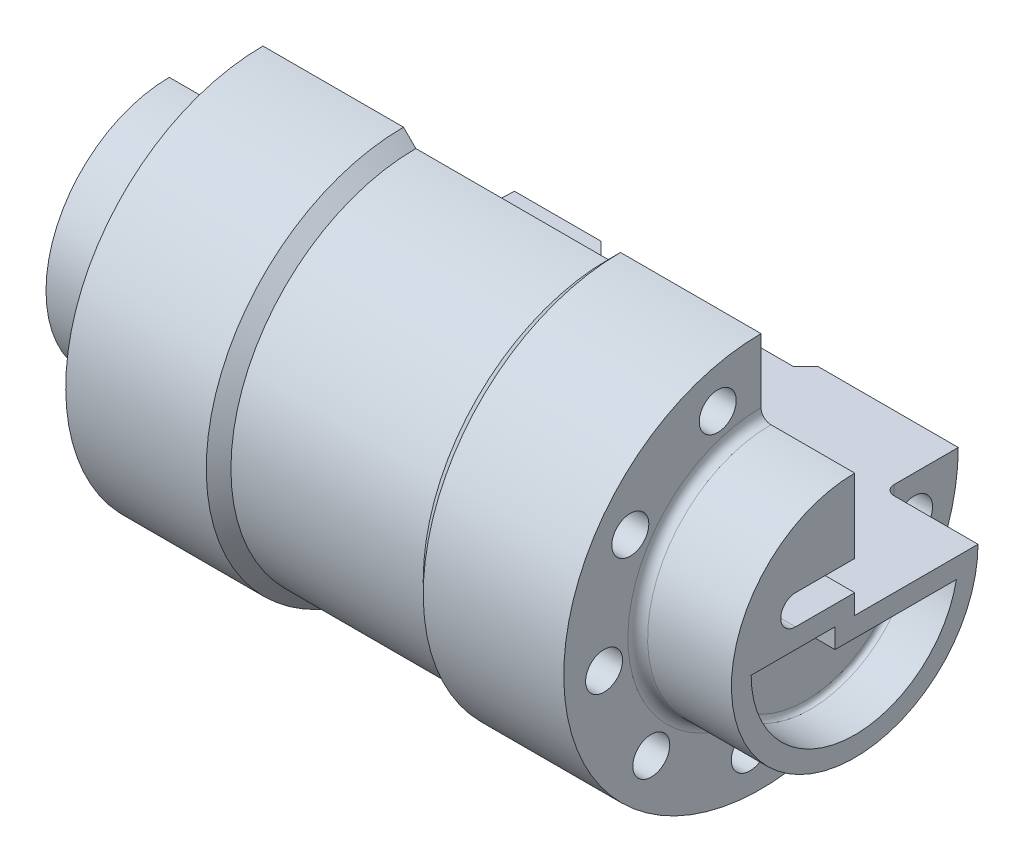
from build123d import *

# Parameters (mm, degrees)
REVOLVE2_ANGLE     = 270
CUT_EXTRUDE1_REACH = 141
CUT_EXTRUDE2_REACH = 122
SKETCH3_R          = 3.75
CUT_EXTRUDE3_DEPTH = 41
CUT_EXTRUDE4_DEPTH = 10
FILLET1_R          = 1


with BuildPart() as part:
    # Sketch1 → Revolve2 (revolve)
    with BuildSketch(Plane(origin=(0, 0, 0), x_dir=(1, 0, 0), z_dir=(0, 1, 0))):
        with BuildLine():
            Line((0, 0), (0, 25))
            Line((0, 25), (17, 25))
            ThreePointArc((17, 25), (18.414213562, 25.585786438), (19, 27))
            Line((19, 27), (19, 40))
            Line((19, 40), (47.5, 40))
            Line((47.5, 40), (50, 37.5))
            Line((50, 37.5), (89, 37.5))
            Line((89, 37.5), (91.5, 40))
            Line((91.5, 40), (120, 40))
            Line((120, 40), (120, 27))
            ThreePointArc((120, 27), (120.585786438, 25.585786438), (122, 25))
            Line((122, 25), (139, 25))
            Line((139, 25), (139, 0))
            Line((139, 0), (0, 0))
        make_face()
    revolve(axis=Axis((139, 0, 0), (-1, 0, 0)), revolution_arc=REVOLVE2_ANGLE)

    # Sketch2 → Cut-Extrude1 (cut, up to next)
    with BuildSketch(Plane(origin=(139, 0, 0), x_dir=(0, 0, -1), z_dir=(1, 0, 0)), mode=Mode.PRIVATE) as cut_extrude1_sk1:
        with BuildLine():
            Line((-12, 4), (0, 4))
            Line((0, 4), (0, 10))
            Line((0, 10), (-12, 10))
            ThreePointArc((-12, 10), (-15, 7), (-12, 4))
        make_face()
    cut_extrude1_tool1 = extrude(cut_extrude1_sk1.sketch, amount=-CUT_EXTRUDE1_REACH, mode=Mode.PRIVATE) & part.part
    add(cut_extrude1_tool1.solids().sort_by_distance((139, 7, 7.193712))[0], mode=Mode.SUBTRACT)

    # Sketch3 → Cut-Extrude2 (cut, up to next)
    with BuildSketch(Plane(origin=(120, 0, 0), x_dir=(0, 0, -1), z_dir=(1, 0, 0)), mode=Mode.PRIVATE) as cut_extrude2_sk1:
        with Locations((-8.783194418, 30.77101714)):
            Circle(SKETCH3_R)
    cut_extrude2_tool1 = extrude(cut_extrude2_sk1.sketch, amount=-CUT_EXTRUDE2_REACH, mode=Mode.PRIVATE) & part.part
    add(cut_extrude2_tool1.solids().sort_by_distance((120, 30.771017, 8.783194))[0], mode=Mode.SUBTRACT)
    # Sketch3 → Cut-Extrude2 (cut, up to next)
    with BuildSketch(Plane(origin=(120, 0, 0), x_dir=(0, 0, -1), z_dir=(1, 0, 0)), mode=Mode.PRIVATE) as cut_extrude2_sk2:
        with Locations((31.040079752, -7.779039077)):
            Circle(SKETCH3_R)
    cut_extrude2_tool2 = extrude(cut_extrude2_sk2.sketch, amount=-CUT_EXTRUDE2_REACH, mode=Mode.PRIVATE) & part.part
    add(cut_extrude2_tool2.solids().sort_by_distance((120, -7.779039, -31.04008))[0], mode=Mode.SUBTRACT)
    # Sketch3 → Cut-Extrude2 (cut, up to next)
    with BuildSketch(Plane(origin=(120, 0, 0), x_dir=(0, 0, -1), z_dir=(1, 0, 0)), mode=Mode.PRIVATE) as cut_extrude2_sk3:
        with Locations((18.777810674, -25.911268327)):
            Circle(SKETCH3_R)
    cut_extrude2_tool3 = extrude(cut_extrude2_sk3.sketch, amount=-CUT_EXTRUDE2_REACH, mode=Mode.PRIVATE) & part.part
    add(cut_extrude2_tool3.solids().sort_by_distance((120, -25.911268, -18.777811))[0], mode=Mode.SUBTRACT)
    # Sketch3 → Cut-Extrude2 (cut, up to next)
    with BuildSketch(Plane(origin=(120, 0, 0), x_dir=(0, 0, -1), z_dir=(1, 0, 0)), mode=Mode.PRIVATE) as cut_extrude2_sk4:
        with Locations((-2.270804711, -31.919327154)):
            Circle(SKETCH3_R)
    cut_extrude2_tool4 = extrude(cut_extrude2_sk4.sketch, amount=-CUT_EXTRUDE2_REACH, mode=Mode.PRIVATE) & part.part
    add(cut_extrude2_tool4.solids().sort_by_distance((120, -31.919327, 2.270805))[0], mode=Mode.SUBTRACT)
    # Sketch3 → Cut-Extrude2 (cut, up to next)
    with BuildSketch(Plane(origin=(120, 0, 0), x_dir=(0, 0, -1), z_dir=(1, 0, 0)), mode=Mode.PRIVATE) as cut_extrude2_sk5:
        with Locations((-22.256885334, -22.991978062)):
            Circle(SKETCH3_R)
    cut_extrude2_tool5 = extrude(cut_extrude2_sk5.sketch, amount=-CUT_EXTRUDE2_REACH, mode=Mode.PRIVATE) & part.part
    add(cut_extrude2_tool5.solids().sort_by_distance((120, -22.991978, 22.256885))[0], mode=Mode.SUBTRACT)
    # Sketch3 → Cut-Extrude2 (cut, up to next)
    with BuildSketch(Plane(origin=(120, 0, 0), x_dir=(0, 0, -1), z_dir=(1, 0, 0)), mode=Mode.PRIVATE) as cut_extrude2_sk6:
        with Locations((-31.828721952, -3.306426908)):
            Circle(SKETCH3_R)
    cut_extrude2_tool6 = extrude(cut_extrude2_sk6.sketch, amount=-CUT_EXTRUDE2_REACH, mode=Mode.PRIVATE) & part.part
    add(cut_extrude2_tool6.solids().sort_by_distance((120, -3.306427, 31.828722))[0], mode=Mode.SUBTRACT)
    # Sketch3 → Cut-Extrude2 (cut, up to next)
    with BuildSketch(Plane(origin=(120, 0, 0), x_dir=(0, 0, -1), z_dir=(1, 0, 0)), mode=Mode.PRIVATE) as cut_extrude2_sk7:
        with Locations((-26.507545832, 17.926238144)):
            Circle(SKETCH3_R)
    cut_extrude2_tool7 = extrude(cut_extrude2_sk7.sketch, amount=-CUT_EXTRUDE2_REACH, mode=Mode.PRIVATE) & part.part
    add(cut_extrude2_tool7.solids().sort_by_distance((120, 17.926238, 26.507546))[0], mode=Mode.SUBTRACT)

    # Sketch4 → Cut-Extrude3 (cut, through all)
    with BuildSketch(Plane(origin=(0, 0, 0), x_dir=(1, 0, 0), z_dir=(0, 1, 0))):
        with BuildLine():
            Line((0, 40), (0, 10))
            ThreePointArc((0, 10), (2.614672282, 10.114159057), (5.20944533, 10.45576741))
            Line((5.20944533, 10.45576741), (6.077686218, 5.531728645))
            ThreePointArc((6.077686218, 5.531728645), (23.263426891, 13.850182233), (33.526230894, 29.950530259))
            Line((33.526230894, 29.950530259), (28.938382586, 32.089879059))
            ThreePointArc((28.938382586, 32.089879059), (29.733411153, 36.00947858), (30, 40))
            Line((30, 40), (0, 40))
        make_face()
    extrude(amount=-CUT_EXTRUDE3_DEPTH, mode=Mode.SUBTRACT)

    # Sketch5 → Cut-Extrude4 (cut)
    with BuildSketch(Plane(origin=(139, 0, 0), x_dir=(0, 0, -1), z_dir=(1, 0, 0))):
        with BuildLine():
            Line((-4, 0), (-12, 0))
            Line((-12, 0), (-21, 0))
            ThreePointArc((-21, 0), (-2.009217424, -20.903661051), (20.615528128, -4))
            Line((20.615528128, -4), (0, -4))
            Line((0, -4), (-4, -4))
            Line((-4, -4), (-4, 0))
        make_face()
    extrude(amount=-CUT_EXTRUDE4_DEPTH, mode=Mode.SUBTRACT)

    # Fillet1
    fillet1_edges = [part.edges().sort_by_distance(p)[0] for p in [
        (129, 0, 12.5),
        (129, -4, -8.307764064),
        (129, -20.903661051, 2.009217424),
        (129, -2, 4),
    ]]
    fillet(fillet1_edges, radius=FILLET1_R)


solid = part.part
